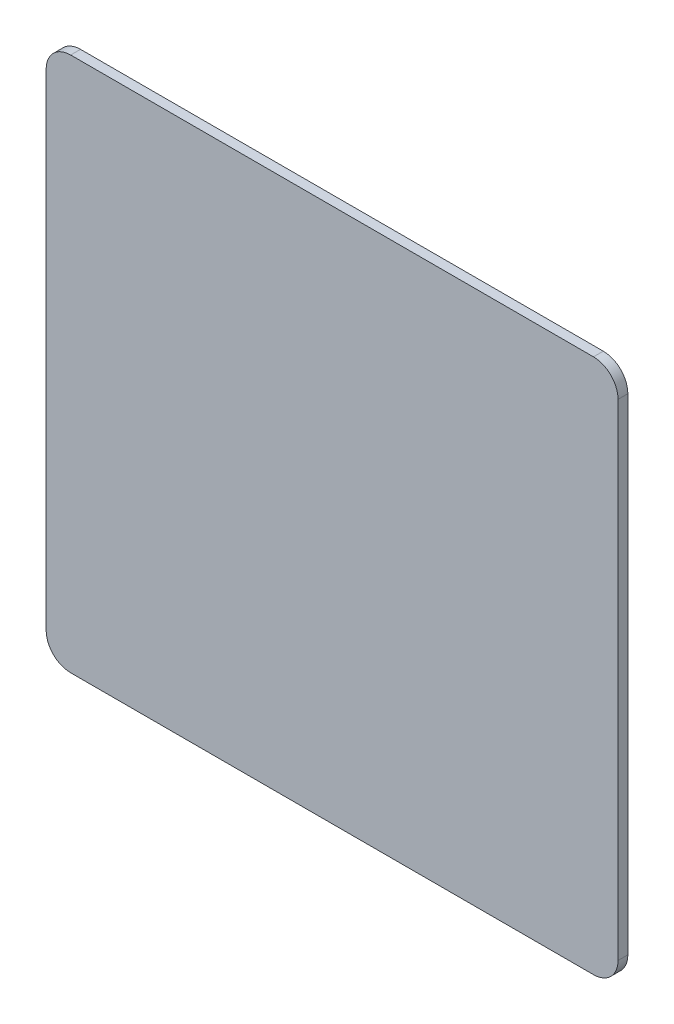
from build123d import *

# Parameters (mm, degrees)
SKETCH_1_W      = 46.6
SKETCH_1_H      = 43.6
EXTRUDE_1_DEPTH = 0.8
FILLET_2_R      = 2


with BuildPart() as part:
    # ｽｹｯﾁ1 → ﾎﾞｽ - 押し出し1 (new body)
    with BuildSketch(Plane.XY):
        Rectangle(SKETCH_1_W, SKETCH_1_H)
    extrude(amount=EXTRUDE_1_DEPTH)

    # ﾌｨﾚｯﾄ2
    fillet_2_edges = [part.edges().sort_by_distance(p)[0] for p in [
        (23.3, -21.8, 0.4),
        (-23.3, -21.8, 0.4),
        (-23.3, 21.8, 0.4),
        (23.3, 21.8, 0.4),
    ]]
    fillet(fillet_2_edges, radius=FILLET_2_R)


solid = part.part
